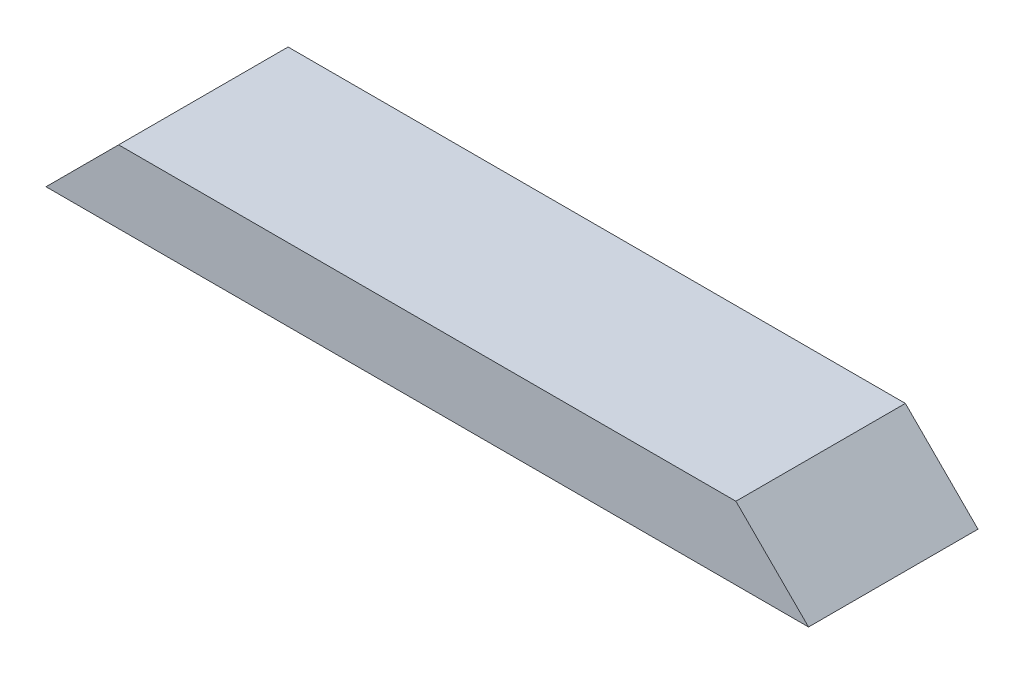
from build123d import *

# Parameters (mm, degrees)
SKETCH1_W           = 400.05
SKETCH1_H           = 88.9
BOSS_EXTRUDE1_DEPTH = 38.1
CUT_EXTRUDE1_DEPTH  = 89.9


with BuildPart() as part:
    # Sketch1 → Boss-Extrude1 (new body)
    with BuildSketch(Plane(origin=(0, 0, 0), x_dir=(1, 0, 0), z_dir=(0, 1, 0))):
        with Locations((200.025, 44.45)):
            Rectangle(SKETCH1_W, SKETCH1_H)
    extrude(amount=BOSS_EXTRUDE1_DEPTH)

    # Sketch2 → Cut-Extrude1 (cut, through all)
    with BuildSketch(Plane.XY):
        Polygon((0, 0), (38.1, 38.1), (0, 38.1), align=None)
        Polygon((400.05, 0), (400.05, 38.1), (361.95, 38.1), align=None)
    extrude(amount=-CUT_EXTRUDE1_DEPTH, mode=Mode.SUBTRACT)


solid = part.part
